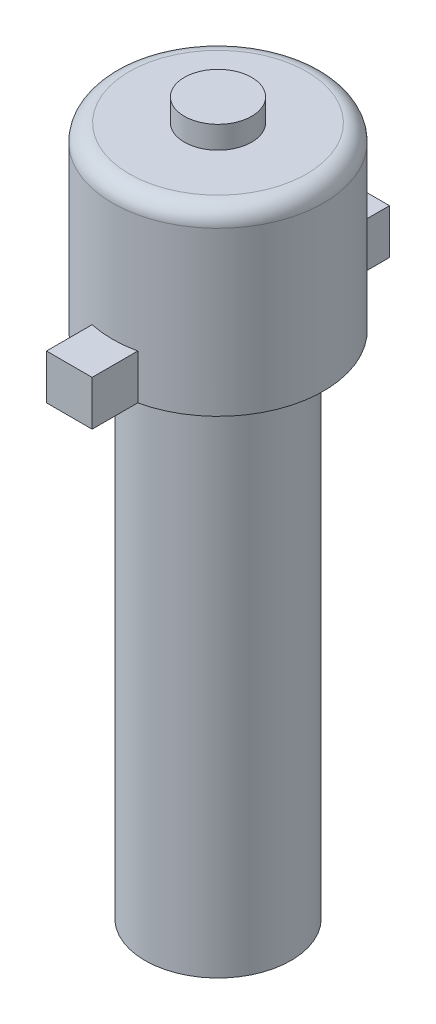
from build123d import *

# Parameters (mm, degrees)
SKETCH1_R           = 3.25
BOSS_EXTRUDE1_DEPTH = 22.686
SKETCH6_R           = 4.7
BOSS_EXTRUDE2_DEPTH = 8
FILLET2_R           = 0.75
SKETCH7_R           = 1.5
BOSS_EXTRUDE3_DEPTH = 1
BOSS_EXTRUDE4_DEPTH = 2


with BuildPart() as part:
    # Sketch1 → Boss-Extrude1 (new body)
    with BuildSketch(Plane(origin=(0, 0, 0), x_dir=(1, 0, 0), z_dir=(0, 1, 0))):
        Circle(SKETCH1_R)
    extrude(amount=BOSS_EXTRUDE1_DEPTH)

    # Sketch6 → Boss-Extrude2 (add)
    with BuildSketch(Plane(origin=(0, 22.686, 0), x_dir=(1, 0, 0), z_dir=(0, 1, 0))):
        Circle(SKETCH6_R)
    extrude(amount=BOSS_EXTRUDE2_DEPTH)

    # Fillet2
    fillet2_edges = [part.edges().sort_by_distance(p)[0] for p in [
        (-4.7, 30.686, 0),
    ]]
    fillet(fillet2_edges, radius=FILLET2_R)

    # Sketch7 → Boss-Extrude3 (add)
    with BuildSketch(Plane(origin=(0, 30.686, 0), x_dir=(1, 0, 0), z_dir=(0, 1, 0))):
        Circle(SKETCH7_R)
    extrude(amount=BOSS_EXTRUDE3_DEPTH)

    # Sketch8 → Boss-Extrude4 (add)
    with BuildSketch(Plane.XZ.offset(-22.686)):
        with BuildLine():
            Line((-1.016, 4.588871757), (-1.016, 6.620871757))
            Line((-1.016, 6.620871757), (1.016, 6.620871757))
            Line((1.016, 6.620871757), (1.016, 4.588871757))
            ThreePointArc((1.016, 4.588871757), (0, 4.7), (-1.016, 4.588871757))
        make_face()
        with BuildLine():
            Line((1.016, -6.620871757), (1.016, -4.588871757))
            ThreePointArc((1.016, -4.588871757), (0, -4.7), (-1.016, -4.588871757))
            Line((-1.016, -4.588871757), (-1.016, -6.620871757))
            Line((-1.016, -6.620871757), (1.016, -6.620871757))
        make_face()
    extrude(amount=-BOSS_EXTRUDE4_DEPTH)


solid = part.part
